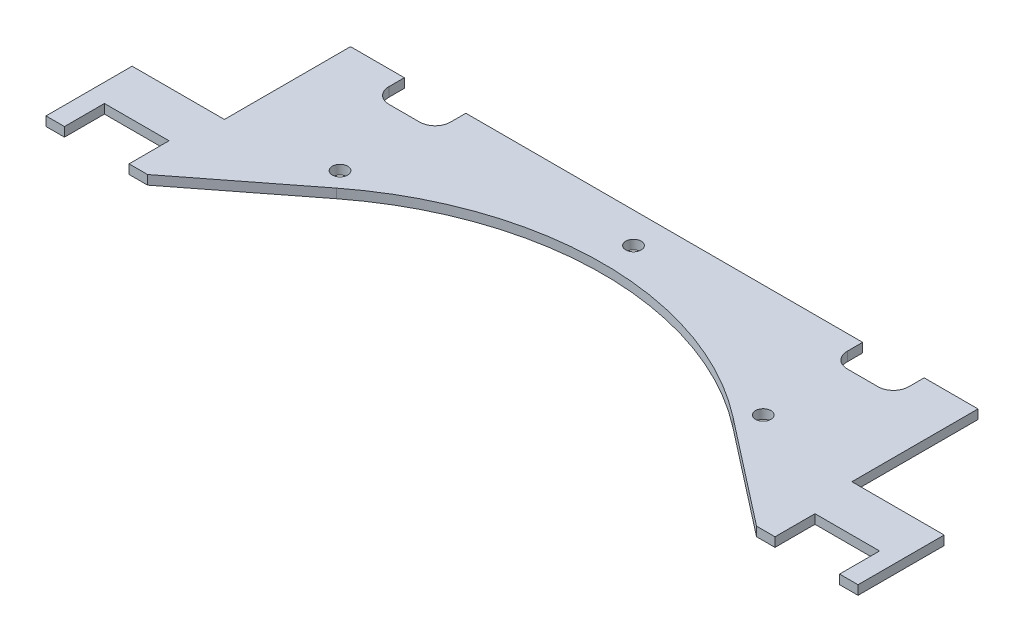
from build123d import *

# Parameters (mm, degrees)
ESQUISSE1_R      = 2.5
EXTRUSION1_DEPTH = 3


with BuildPart() as part:
    # Esquisse1 → Extrusion1 (new body)
    with BuildSketch(Plane(origin=(0, 0, 0), x_dir=(1, 0, 0), z_dir=(0, 1, 0))):
        with BuildLine():
            Line((-64.494367887, 52.858171056), (-99, 26))
            Line((-99, 26), (-105, 26))
            Line((-105, 26), (-105, 39))
            Line((-105, 39), (-126, 39))
            Line((-126, 39), (-126, 26))
            Line((-126, 26), (-132, 26))
            Line((-132, 26), (-132, 54))
            Line((-132, 54), (-102, 54))
            Line((-102, 54), (-102, 95))
            Line((-102, 95), (-84.5, 95))
            Line((-84.5, 95), (-84.5, 90))
            ThreePointArc((-84.5, 90), (-83.035533906, 86.464466094), (-79.5, 85))
            Line((-79.5, 85), (-69.5, 85))
            ThreePointArc((-69.5, 85), (-65.964466094, 86.464466094), (-64.5, 90))
            Line((-64.5, 90), (-64.5, 95))
            Line((-64.5, 95), (64.5, 95))
            Line((64.5, 95), (64.5, 90))
            ThreePointArc((64.5, 90), (65.964466094, 86.464466094), (69.5, 85))
            Line((69.5, 85), (79.5, 85))
            ThreePointArc((79.5, 85), (83.035533906, 86.464466094), (84.5, 90))
            Line((84.5, 90), (84.5, 95))
            Line((84.5, 95), (102, 95))
            Line((102, 95), (102, 54))
            Line((102, 54), (132, 54))
            Line((132, 54), (132, 26))
            Line((132, 26), (126, 26))
            Line((126, 26), (126, 39))
            Line((126, 39), (105, 39))
            Line((105, 39), (105, 26))
            Line((105, 26), (99, 26))
            Line((99, 26), (64.494367887, 52.858171056))
            ThreePointArc((64.494367887, 52.858171056), (0, 75), (-64.494367887, 52.858171056))
        make_face()
        with Locations((-68.793992413, 58.382049127)):
            Circle(ESQUISSE1_R, mode=Mode.SUBTRACT)
        with Locations((68.793992413, 58.382049127)):
            Circle(ESQUISSE1_R, mode=Mode.SUBTRACT)
        with Locations((0, 85)):
            Circle(ESQUISSE1_R, mode=Mode.SUBTRACT)
    extrude(amount=EXTRUSION1_DEPTH)


solid = part.part
